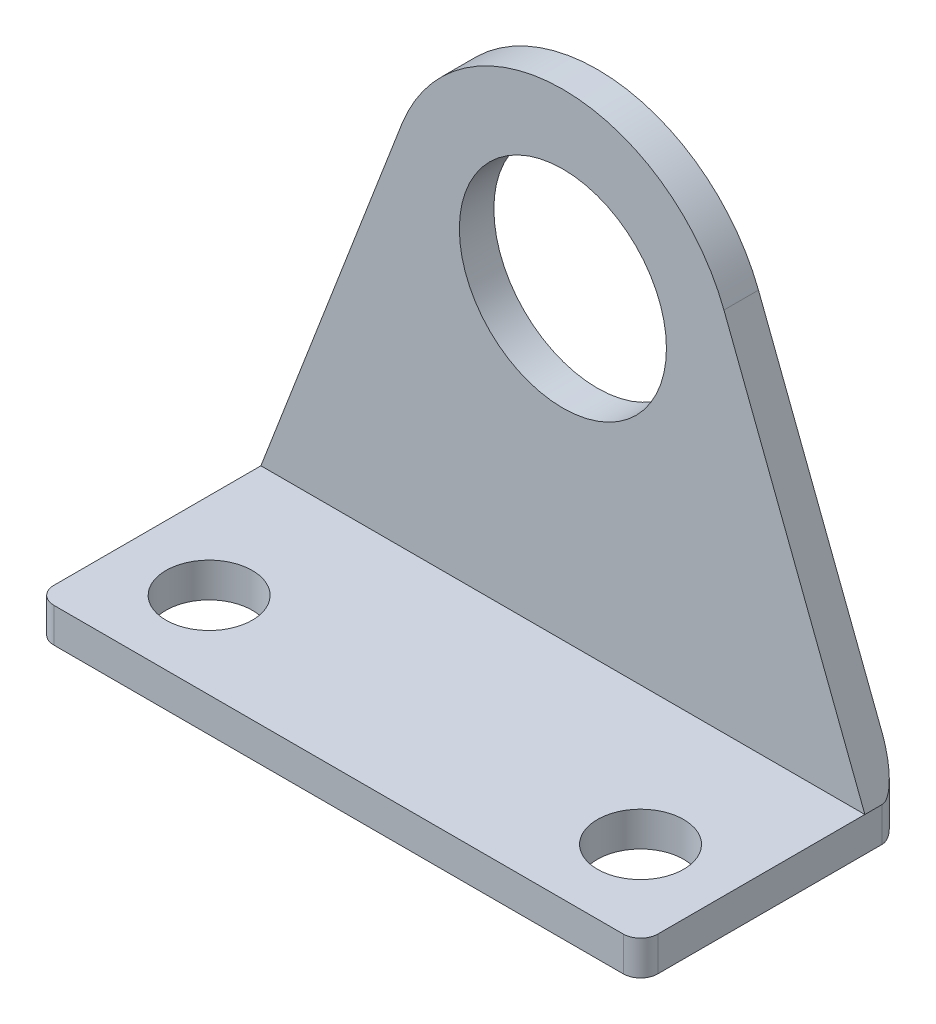
from build123d import *

# Parameters (mm, degrees)
SKETCH1_W           = 35
SKETCH1_H           = 15
BOSS_EXTRUDE1_DEPTH = 2
BOSS_EXTRUDE2_DEPTH = 2
FILLET1_R           = 10
FILLET2_R           = 1
FILLET3_R           = 1
SKETCH4_R           = 2.5
CUT_EXTRUDE1_DEPTH  = 3
SKETCH5_R           = 6
CUT_EXTRUDE2_DEPTH  = 3


with BuildPart() as part:
    # Sketch1 → Boss-Extrude1 (new body)
    with BuildSketch(Plane(origin=(0, 0, 0), x_dir=(1, 0, 0), z_dir=(0, 1, 0))):
        with Locations((17.5, 7.5)):
            Rectangle(SKETCH1_W, SKETCH1_H)
    extrude(amount=BOSS_EXTRUDE1_DEPTH)

    # Sketch3 → Boss-Extrude2 (add)
    with BuildSketch(Plane(origin=(0, 0, -15), x_dir=(-1, 0, 0), z_dir=(0, 0, -1))):
        Polygon((0, 2), (-35, 2), (-17.5, 47.5), align=None)
    extrude(amount=-BOSS_EXTRUDE2_DEPTH)

    # Fillet1
    fillet1_edges = [part.edges().sort_by_distance(p)[0] for p in [
        (17.5, 47.5, -14),
    ]]
    fillet(fillet1_edges, radius=FILLET1_R)

    # Fillet2
    fillet2_edges = [part.edges().sort_by_distance(p)[0] for p in [
        (17.5, 0, -15),
        (0, 1, -15),
        (35, 1, -15),
    ]]
    fillet(fillet2_edges, radius=FILLET2_R)

    # Fillet3
    fillet3_edges = [part.edges().sort_by_distance(p)[0] for p in [
        (35, 1, 0),
        (0, 1, 0),
    ]]
    fillet(fillet3_edges, radius=FILLET3_R)

    # Sketch4 → Cut-Extrude1 (cut, through all)
    with BuildSketch(Plane(origin=(0, 2, 0), x_dir=(1, 0, 0), z_dir=(0, 1, 0))):
        with Locations((5, 5)):
            Circle(SKETCH4_R)
        with Locations((30, 5)):
            Circle(SKETCH4_R)
    extrude(amount=-CUT_EXTRUDE1_DEPTH, mode=Mode.SUBTRACT)

    # Sketch5 → Cut-Extrude2 (cut, through all)
    with BuildSketch(Plane.XY.offset(-13)):
        with Locations((17.5, 19.643223446)):
            Circle(SKETCH5_R)
    extrude(amount=-CUT_EXTRUDE2_DEPTH, mode=Mode.SUBTRACT)


solid = part.part
